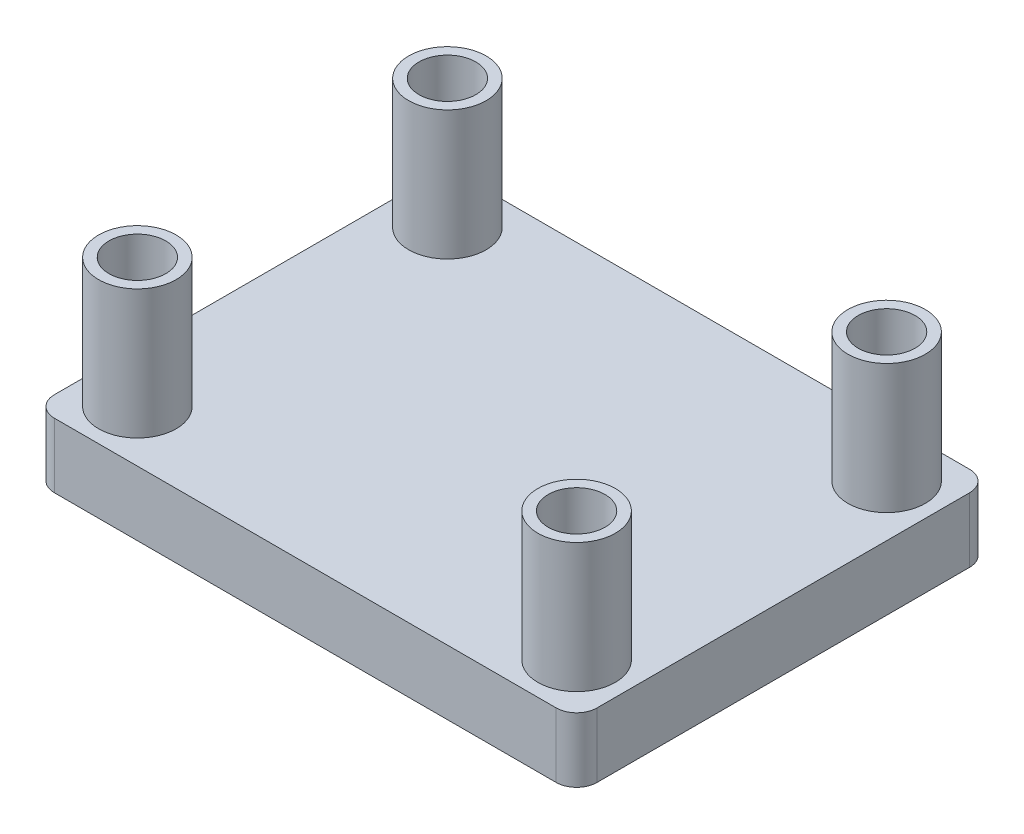
from build123d import *

# Parameters (mm, degrees)
SKETCH1_W           = 26.67
SKETCH1_H           = 20.32
BOSS_EXTRUDE1_DEPTH = 3.175
SKETCH2_R           = 1.905
SKETCH2_R_2         = 1.397
BOSS_EXTRUDE2_DEPTH = 6.35
FILLET1_R           = 1


with BuildPart() as part:
    # Sketch1 → Boss-Extrude1 (new body)
    with BuildSketch(Plane(origin=(0, 0, 0), x_dir=(1, 0, 0), z_dir=(0, 1, 0))):
        with Locations((-10.451352941, 1.434352941)):
            Rectangle(SKETCH1_W, SKETCH1_H)
    extrude(amount=BOSS_EXTRUDE1_DEPTH)

    # Sketch2 → Boss-Extrude2 (add)
    with BuildSketch(Plane(origin=(0, 3.175, 0), x_dir=(1, 0, 0), z_dir=(0, 1, 0))):
        with Locations((-21.246352941, 9.054352941)):
            Circle(SKETCH2_R)
        with Locations((-21.246352941, 9.054352941)):
            Circle(SKETCH2_R_2, mode=Mode.SUBTRACT)
        with Locations((0.343647059, 9.054352941)):
            Circle(SKETCH2_R)
        with Locations((0.343647059, 9.054352941)):
            Circle(SKETCH2_R_2, mode=Mode.SUBTRACT)
        with Locations((0.343647059, -6.185647059)):
            Circle(SKETCH2_R)
        with Locations((0.343647059, -6.185647059)):
            Circle(SKETCH2_R_2, mode=Mode.SUBTRACT)
        with Locations((-21.246352941, -6.185647059)):
            Circle(SKETCH2_R)
        with Locations((-21.246352941, -6.185647059)):
            Circle(SKETCH2_R_2, mode=Mode.SUBTRACT)
    extrude(amount=BOSS_EXTRUDE2_DEPTH)

    # Fillet1
    fillet1_edges = [part.edges().sort_by_distance(p)[0] for p in [
        (-23.786352941, 1.5875, -11.594352941),
        (2.883647059, 1.5875, -11.594352941),
        (2.883647059, 1.5875, 8.725647059),
        (-23.786352941, 1.5875, 8.725647059),
    ]]
    fillet(fillet1_edges, radius=FILLET1_R)


solid = part.part
